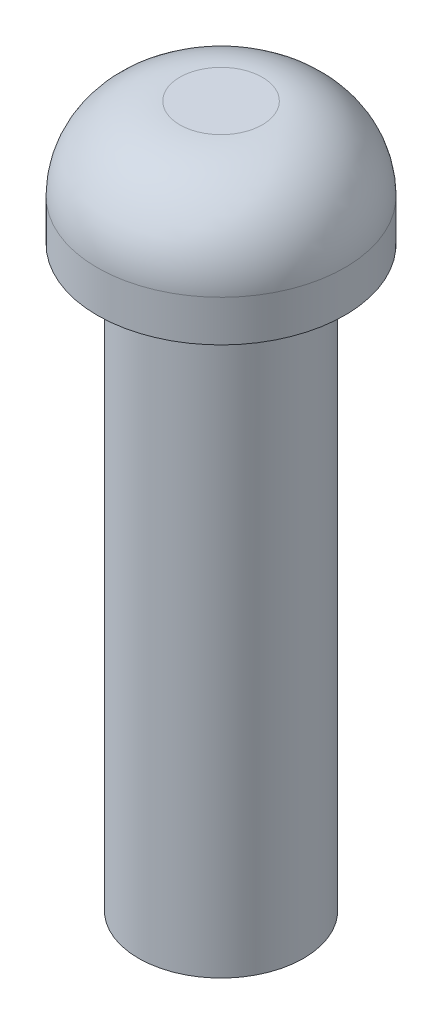
from build123d import *

# Parameters (mm, degrees)
ESQUISSE1_R        = 15
BOSS_EXTRU_1_DEPTH = 15
CONG_1_R           = 10
ESQUISSE3_R        = 10
BOSS_EXTRU_3_DEPTH = 70


with BuildPart() as part:
    # Esquisse1 → Boss.-Extru.1 (new body)
    with BuildSketch(Plane(origin=(0, 0, 0), x_dir=(1, 0, 0), z_dir=(0, 1, 0))):
        Circle(ESQUISSE1_R)
    extrude(amount=BOSS_EXTRU_1_DEPTH)

    # Congé1
    cong_1_edges = [part.edges().sort_by_distance(p)[0] for p in [
        (-15, 15, 0),
    ]]
    fillet(cong_1_edges, radius=CONG_1_R)

    # Esquisse3 → Boss.-Extru.3 (add)
    with BuildSketch(Plane.XZ):
        Circle(ESQUISSE3_R)
    extrude(amount=BOSS_EXTRU_3_DEPTH)


solid = part.part
